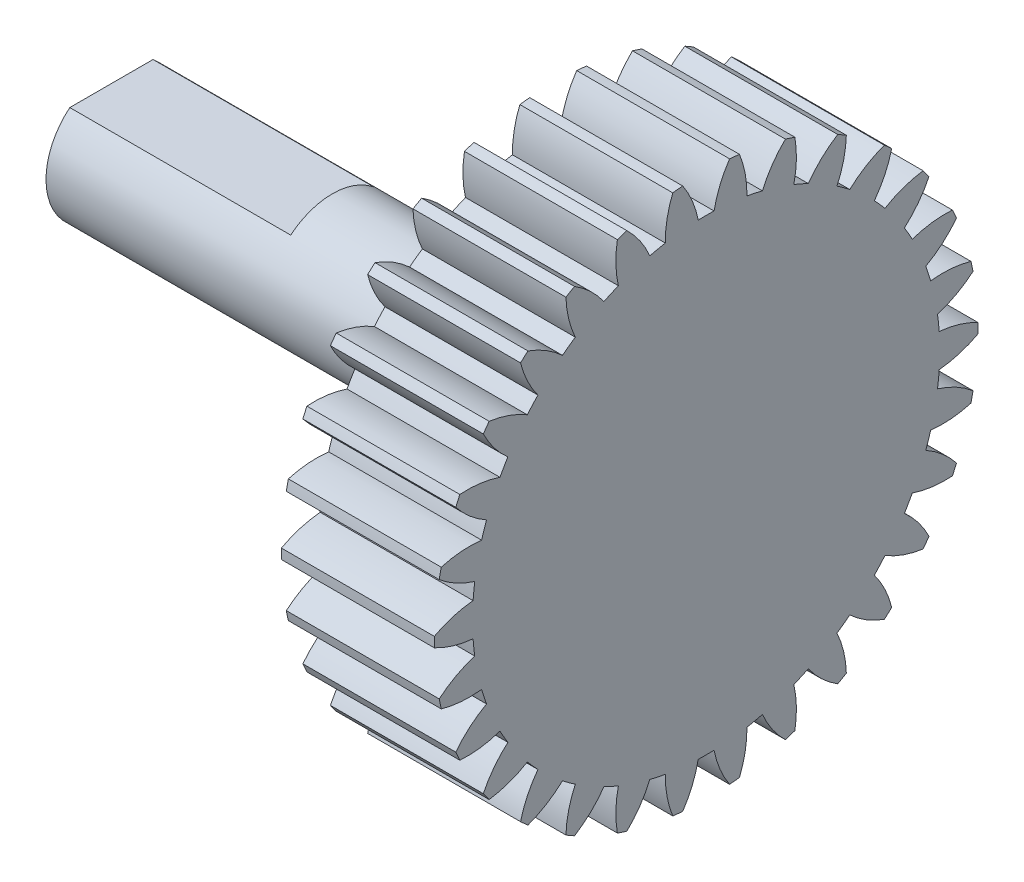
from build123d import *

# Parameters (mm, degrees)
BASPROSKE_W              = 9
BASPROSKE_H              = 16
TOOTHCUT_DEPTH           = 25.351591324
TEETHCUTS_COUNT          = 30
TEETHCUTS_ANGLE          = 348
BORSKE_R                 = 4
BORE_DEPTH               = 50.0000508
BOSS_EXTRUDE3_DEPTH      = 26
BOSS_EXTRUDE3_DEPTH_BACK = 9
BOSS_EXTRUDE4_DEPTH      = 13
BOSS_EXTRUDE4_DEPTH_BACK = 9
BOSS_EXTRUDE5_DEPTH      = 1
BOSS_EXTRUDE5_DEPTH_BACK = 9
SKETCH2_6_R              = 4.5


with BuildPart() as part:
    # BasProSke → Base-Revolve (revolve)
    with BuildSketch(Plane(origin=(0, 0, 0), x_dir=(1, 0, 0), z_dir=(0, 1, 0))):
        with Locations((4.5, 8)):
            Rectangle(BASPROSKE_W, BASPROSKE_H)
    revolve(axis=Axis((-10, 0, 0), (1, 0, 0)))

    # TooCutSke → ToothCut (cut, through all)
    with BuildSketch(Plane(origin=(0, 0, 0), x_dir=(0, 0, -1), z_dir=(1, 0, 0))):
        with BuildLine():
            ThreePointArc((0.466400716, 13.741086979), (0, 13.749), (-0.466400716, 13.741086979))
            ThreePointArc((-0.466400716, 13.741086979), (-0.819142092, 14.899954875), (-1.3974676, 15.964351834))
            ThreePointArc((-1.3974676, 15.964351834), (0, 16.0254), (1.3974676, 15.964351834))
            ThreePointArc((1.3974676, 15.964351834), (0.819142092, 14.899954875), (0.466400716, 13.741086979))
        make_face()
    toothcut = extrude(amount=TOOTHCUT_DEPTH, mode=Mode.SUBTRACT)

    # TeethCuts: ToothCut ×30 about axis
    teethcuts_axis = Axis((-10, 0, 0), (1, 0, 0))
    for i in range(1, TEETHCUTS_COUNT):
        add(toothcut.rotate(teethcuts_axis, i * TEETHCUTS_ANGLE / (TEETHCUTS_COUNT - 1)), mode=Mode.SUBTRACT)

    # BorSke → Bore (cut, symmetric)
    with BuildSketch(Plane(origin=(0, 0, 0), x_dir=(0, 0, -1), z_dir=(1, 0, 0))):
        Circle(BORSKE_R)
    extrude(amount=BORE_DEPTH, both=True, mode=Mode.SUBTRACT)



with BuildPart() as body_2:
    # Sketch2 → Boss-Extrude3 (new, two sides: drawn at the far end of the back side and taken through both)
    with BuildSketch(Plane.ZY.offset(-BOSS_EXTRUDE3_DEPTH_BACK)):
        with BuildLine():
            Line((2.45, 2.969848481), (-2.45, 2.969848481))
            ThreePointArc((-2.45, 2.969848481), (-1.641645516, -3.48245603), (3.85, 0))
            ThreePointArc((3.85, 0), (3.48245603, 1.641645516), (2.45, 2.969848481))
        make_face()
    extrude(amount=BOSS_EXTRUDE3_DEPTH + BOSS_EXTRUDE3_DEPTH_BACK)

    # Sketch2_5 → Boss-Extrude4 (add, two sides: drawn at the far end of the back side and taken through both)
    with BuildSketch(Plane.ZY.offset(-BOSS_EXTRUDE4_DEPTH_BACK)):
        with BuildLine():
            ThreePointArc((2.45, 2.969848481), (0, 3.85), (-2.45, 2.969848481))
            Line((-2.45, 2.969848481), (2.45, 2.969848481))
        make_face()
    extrude(amount=BOSS_EXTRUDE4_DEPTH + BOSS_EXTRUDE4_DEPTH_BACK)


with BuildPart() as part_1:
    add(part.part)

    add(body_2.part)  # Boss-Extrude5 merges body 2
    # Sketch2_6 → Boss-Extrude5 (add, two sides: drawn at the far end of the back side and taken through both)
    with BuildSketch(Plane.ZY.offset(-BOSS_EXTRUDE5_DEPTH_BACK)):
        Circle(SKETCH2_6_R)
        with BuildLine():
            ThreePointArc((3.85, 0), (-1.641645516, -3.48245603), (-2.45, 2.969848481))
            ThreePointArc((-2.45, 2.969848481), (0, 3.85), (2.45, 2.969848481))
            ThreePointArc((2.45, 2.969848481), (3.48245603, 1.641645516), (3.85, 0))
        make_face(mode=Mode.SUBTRACT)
    extrude(amount=BOSS_EXTRUDE5_DEPTH + BOSS_EXTRUDE5_DEPTH_BACK)


solid = part_1.part
